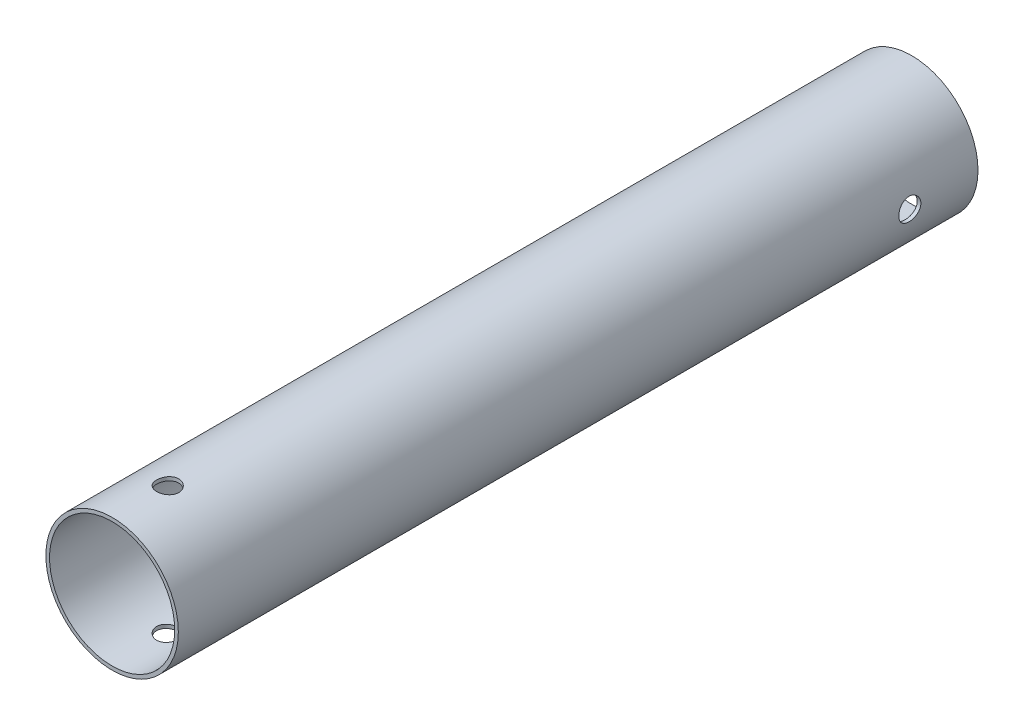
from build123d import *

# Parameters (mm, degrees)
CROQUIS1_R                 = 9.525
CROQUIS1_R_2               = 9
SALIENTE_EXTRUIR1_DEPTH    = 115
CROQUIS2_R                 = 1.5875
CORTAR_EXTRUIR1_DEPTH      = 10.525
CORTAR_EXTRUIR1_DEPTH_BACK = 10.525
CROQUIS3_R                 = 1.5875
CORTAR_EXTRUIR2_DEPTH      = 10.5250001
CORTAR_EXTRUIR2_DEPTH_BACK = 10.5250001


with BuildPart() as part:
    # Croquis1 → Saliente-Extruir1 (new body)
    with BuildSketch(Plane.XY):
        Circle(CROQUIS1_R)
        Circle(CROQUIS1_R_2, mode=Mode.SUBTRACT)
    extrude(amount=SALIENTE_EXTRUIR1_DEPTH)

    # Croquis2 → Cortar-Extruir1 (cut, two sides)
    with BuildSketch(Plane(origin=(0, 0, 0), x_dir=(0, 0, -1), z_dir=(1, 0, 0))) as cortar_extruir1_sk:
        with Locations((-9.8, 0)):
            Circle(CROQUIS2_R)
    extrude(amount=CORTAR_EXTRUIR1_DEPTH, mode=Mode.SUBTRACT)
    extrude(cortar_extruir1_sk.sketch, amount=-CORTAR_EXTRUIR1_DEPTH_BACK, mode=Mode.SUBTRACT)

    # Croquis3 → Cortar-Extruir2 (cut, two sides)
    with BuildSketch(Plane(origin=(0, 0, 0), x_dir=(1, 0, 0), z_dir=(0, 1, 0))) as cortar_extruir2_sk:
        with Locations((0, -107.0025)):
            Circle(CROQUIS3_R)
    extrude(amount=CORTAR_EXTRUIR2_DEPTH, mode=Mode.SUBTRACT)
    extrude(cortar_extruir2_sk.sketch, amount=-CORTAR_EXTRUIR2_DEPTH_BACK, mode=Mode.SUBTRACT)


solid = part.part
